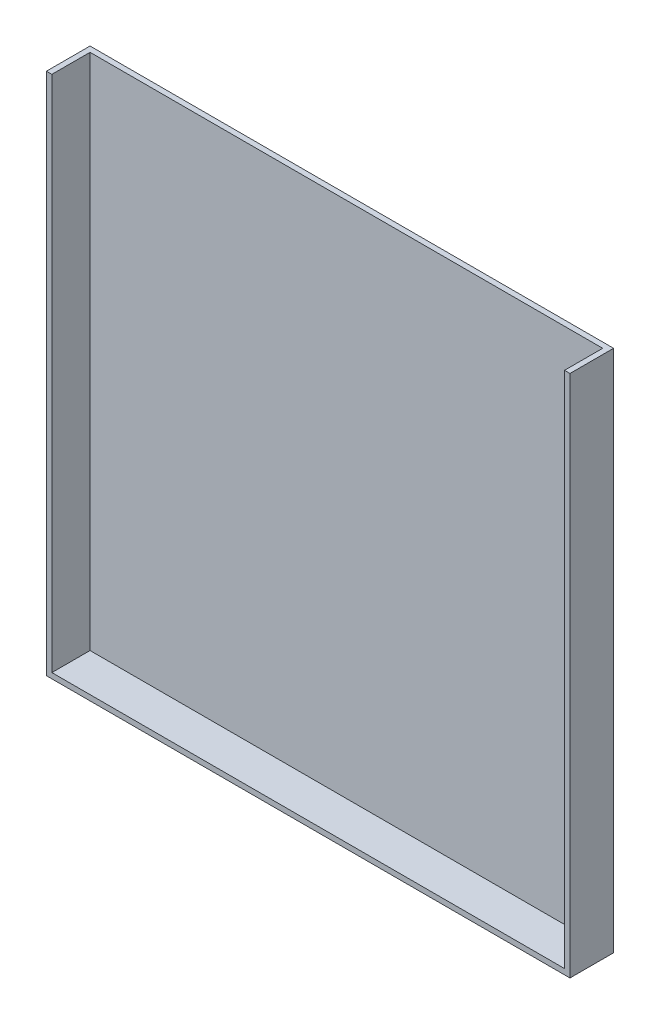
from build123d import *

# Parameters (mm, degrees)
SKETCH2_W           = 304.8
SKETCH2_H           = 304.8
BOSS_EXTRUDE1_DEPTH = 25.4
SHELL1_T            = -3.175


with BuildPart() as part:
    # Sketch2 → Boss-Extrude1 (new body)
    with BuildSketch(Plane.XY):
        with Locations((152.4, 152.4)):
            Rectangle(SKETCH2_W, SKETCH2_H)
    extrude(amount=BOSS_EXTRUDE1_DEPTH)

    # Shell1
    shell1_openings = [part.faces().sort_by_distance(p)[0] for p in [
        (152.4, 152.4, 25.4),
        (152.4, 304.8, 12.7),
    ]]
    offset(amount=SHELL1_T, openings=shell1_openings, kind=Kind.INTERSECTION)


solid = part.part
